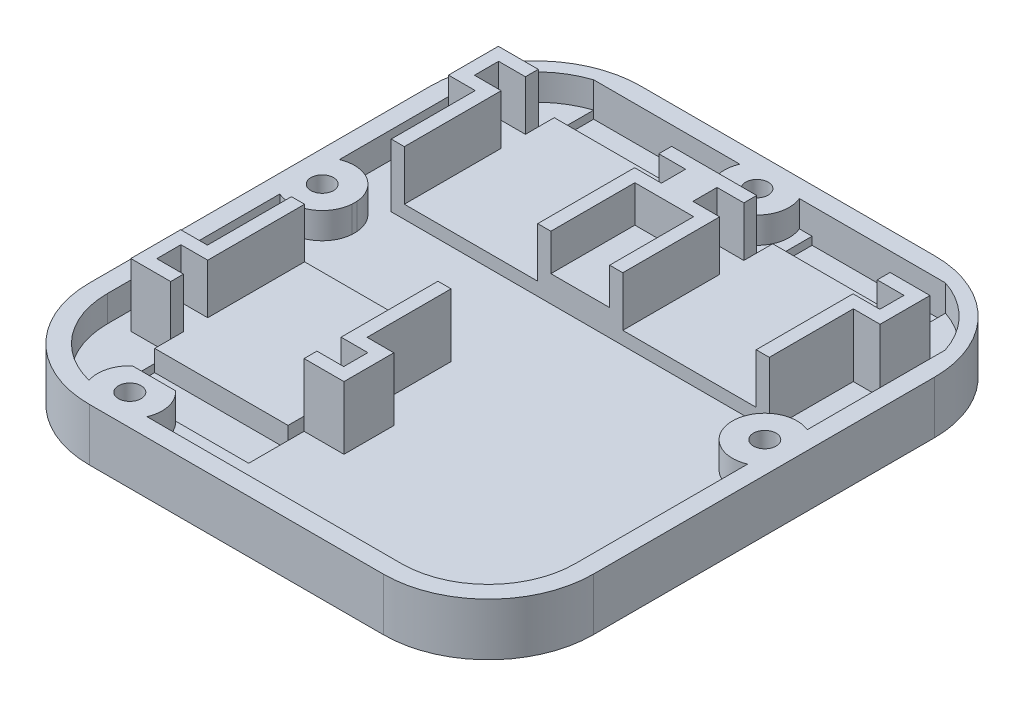
from build123d import *

# Parameters (mm, degrees)
BASE_DEPTH                                        = 10
HOLE_FOR_ACTUATOR_COVERS_DEPTH                    = 5
SIDE_CLAMPS_DEPTH                                 = 7
SKETCH14_W                                        = 25.4
SKETCH14_H                                        = 7.5
PULLEY_CLEARANCES_DEPTH                           = 6.5
CSK_FOR_8_FLAT_HEAD_SOCKET_CAP_SCREW1_D           = 4.3053
CSK_FOR_8_FLAT_HEAD_SOCKET_CAP_SCREW1_CSINK_D     = 9.1186
CSK_FOR_8_FLAT_HEAD_SOCKET_CAP_SCREW1_CSINK_ANGLE = 82
ACTUATOR_GROOVE_DEPTH                             = 2.5
MATERIAL_CUTAWAY_DEPTH                            = 5


with BuildPart() as part:
    # Sketch1 → base (new body)
    with BuildSketch(Plane(origin=(0, 0, 0), x_dir=(1, 0, 0), z_dir=(0, 1, 0))):
        with BuildLine():
            Line((-28, 52.5), (28, 52.5))
            ThreePointArc((28, 52.5), (42.142135624, 46.642135624), (48, 32.5))
            Line((48, 32.5), (48, -32.5))
            ThreePointArc((48, -32.5), (42.142135624, -46.642135624), (28, -52.5))
            Line((28, -52.5), (-28, -52.5))
            ThreePointArc((-28, -52.5), (-42.142135624, -46.642135624), (-48, -32.5))
            Line((-48, -32.5), (-48, 32.5))
            ThreePointArc((-48, 32.5), (-42.142135624, 46.642135624), (-28, 52.5))
        make_face()
    extrude(amount=BASE_DEPTH)

    # Sketch10 → hole for actuator covers (cut)
    with BuildSketch(Plane(origin=(0, 10, 0), x_dir=(1, 0, 0), z_dir=(0, 1, 0))):
        Polygon((-5.6, 5.5), (-5.6, 13), (-8.6, 13), (-33, 13), (-36, 13), (-36, 5.5), align=None)
        Polygon((33, 13), (36, 13), (36, 5.5), (5.6, 5.5), (5.6, 13), (8.6, 13), align=None)
        Polygon((-5.6, -6), (-8.6, -6), (-33, -6), (-36, -6), (-36, 1.5), (-5.6, 1.5), align=None)
    extrude(amount=-HOLE_FOR_ACTUATOR_COVERS_DEPTH, mode=Mode.SUBTRACT)

    # Sketch13 → side clamps (add)
    with BuildSketch(Plane(origin=(0, 10, 0), x_dir=(1, 0, 0), z_dir=(0, 1, 0))):
        Polygon((-8.1, -24.45), (-3, -24.45), (-3, -29.05), (-8.1, -29.05), (-8.1, -31.5), (-0.5, -31.5), (-0.5, -22), (-5.6, -22), (-5.6, -6), (-8.1, -6), align=None)
        Polygon((-41.1, 29), (-41.1, 38.5), (-33.5, 38.5), (-33.5, 36.05), (-38.6, 36.05), (-38.6, 31.45), (-33.5, 31.45), (-33.5, 13), (-36, 13), (-36, 29), align=None)
        Polygon((-8.1, 13), (-8.1, 31.45), (-3, 31.45), (-3, 36.05), (-8.1, 36.05), (-8.1, 38.5), (8.1, 38.5), (8.1, 36.05), (3, 36.05), (3, 31.45), (8.1, 31.45), (8.1, 13), (5.6, 13), (5.6, 29), (-5.6, 29), (-5.6, 13), align=None)
        Polygon((33.5, 13), (33.5, 31.45), (38.6, 31.45), (38.6, 36.05), (33.5, 36.05), (33.5, 38.5), (41.1, 38.5), (41.1, 29), (36, 29), (36, 13), align=None)
        Polygon((-38.6, -24.45), (-38.6, -29.05), (-33.5, -29.05), (-33.5, -31.5), (-41.1, -31.5), (-41.1, -22), (-36, -22), (-36, -6), (-33.5, -6), (-33.5, -24.45), align=None)
    extrude(amount=SIDE_CLAMPS_DEPTH)

    # Sketch14 → pulley clearances (cut)
    with BuildSketch(Plane(origin=(0, 10, 0), x_dir=(1, 0, 0), z_dir=(0, 1, 0))):
        with Locations((-20.8, -38.3)):
            Rectangle(SKETCH14_W, SKETCH14_H)
        with Locations((-20.8, 45.3)):
            Rectangle(SKETCH14_W, SKETCH14_H)
        with Locations((20.8, 45.3)):
            Rectangle(SKETCH14_W, SKETCH14_H)
    extrude(amount=-PULLEY_CLEARANCES_DEPTH, mode=Mode.SUBTRACT)

    # CSK for #8 Flat Head Socket Cap Screw1 (through all)
    with Locations(Plane(origin=(0, 0, 0), x_dir=(-1, 0, 0), z_dir=(0, -1, 0))):
        with Locations((26.142135624, -46.642135624), (42.142135624, 6), (0, 46.642135624), (-42.142135624, 6)):
            CounterSinkHole(CSK_FOR_8_FLAT_HEAD_SOCKET_CAP_SCREW1_D / 2, CSK_FOR_8_FLAT_HEAD_SOCKET_CAP_SCREW1_CSINK_D / 2, counter_sink_angle=CSK_FOR_8_FLAT_HEAD_SOCKET_CAP_SCREW1_CSINK_ANGLE)

    # Sketch18 → actuator groove (cut)
    with BuildSketch(Plane(origin=(0, 10, 0), x_dir=(1, 0, 0), z_dir=(0, 1, 0))):
        Polygon((-33.5, 31.45), (-33.5, 13), (-8.1, 13), (-8.1, 31.45), (-3, 31.45), (-3, 36.05), (-8.1, 36.05), (-8.1, 41.55), (-33.5, 41.55), (-33.5, 36.05), (-38.6, 36.05), (-38.6, 31.45), align=None)
        Polygon((38.6, 31.45), (38.6, 36.05), (33.5, 36.05), (33.5, 41.55), (8.1, 41.55), (8.1, 36.05), (3, 36.05), (3, 31.45), (8.1, 31.45), (8.1, 13), (33.5, 13), (33.5, 31.45), align=None)
        Polygon((-33.5, -6), (-33.5, -24.45), (-38.6, -24.45), (-38.6, -29.05), (-33.5, -29.05), (-33.5, -34.55), (-8.1, -34.55), (-8.1, -29.05), (-3, -29.05), (-3, -24.45), (-8.1, -24.45), (-8.1, -6), align=None)
    extrude(amount=-ACTUATOR_GROOVE_DEPTH, mode=Mode.SUBTRACT)

    # Sketch20 → material cutaway (cut)
    with BuildSketch(Plane(origin=(0, 10, 0), x_dir=(1, 0, 0), z_dir=(0, 1, 0))):
        with BuildLine():
            Line((-36, -6), (-5.6, -6))
            Line((-5.6, -6), (-5.6, -22))
            Line((-5.6, -22), (-0.5, -22))
            Line((-0.5, -22), (-0.5, -31.5))
            Line((-0.5, -31.5), (-8.1, -31.5))
            Line((-8.1, -31.5), (-8.1, -42.05))
            Line((-8.1, -42.05), (-22.032619784, -42.05))
            ThreePointArc((-22.032619784, -42.05), (-20.127795479, -45.29917522), (-20.469568377, -49.05))
            Line((-20.469568377, -49.05), (28, -49.05))
            ThreePointArc((28, -49.05), (39.702617229, -44.202617229), (44.55, -32.5))
            Line((44.55, -32.5), (44.55, 0.327432754))
            ThreePointArc((44.55, 0.327432754), (38.952298885, 0.727356298), (36, 5.5))
            ThreePointArc((36, 5.5), (38.535011833, 10.996447536), (44.55, 11.672567246))
            Line((44.55, 11.672567246), (44.55, 37.948525732))
            ThreePointArc((44.55, 37.948525732), (40.344819956, 44.812963205), (33.5, 49.05))
            Line((33.5, 49.05), (8.1, 49.05))
            Line((8.1, 49.05), (5.672567246, 49.05))
            ThreePointArc((5.672567246, 49.05), (0, 40.479682377), (-5.672567246, 49.05))
            Line((-5.672567246, 49.05), (-8.1, 49.05))
            Line((-8.1, 49.05), (-33.5, 49.05))
            ThreePointArc((-33.5, 49.05), (-40.344819956, 44.812963205), (-44.55, 37.948525732))
            Line((-44.55, 37.948525732), (-44.55, 11.672567246))
            ThreePointArc((-44.55, 11.672567246), (-35.979682377, 6), (-44.55, 0.327432754))
            Line((-44.55, 0.327432754), (-44.55, -32.5))
            ThreePointArc((-44.55, -32.5), (-41.039944494, -42.691287828), (-31.998658901, -48.559677051))
            ThreePointArc((-31.998658901, -48.559677051), (-32.093980526, -45.044834063), (-30.251651463, -42.05))
            Line((-30.251651463, -42.05), (-33.5, -42.05))
            Line((-33.5, -42.05), (-33.5, -31.5))
            Line((-33.5, -31.5), (-41.1, -31.5))
            Line((-41.1, -31.5), (-41.1, -22))
            Line((-41.1, -22), (-36, -22))
            Line((-36, -22), (-36, -6))
        make_face()
        Polygon((-8.1, 38.5), (-8.1, 41.55), (-33.5, 41.55), (-33.5, 38.5), (-41.1, 38.5), (-41.1, 29), (-36, 29), (-36, 13), (36, 13), (36, 29), (41.1, 29), (41.1, 38.5), (33.5, 38.5), (33.5, 41.55), (8.1, 41.55), (8.1, 38.5), align=None, mode=Mode.SUBTRACT)
    extrude(amount=-MATERIAL_CUTAWAY_DEPTH, mode=Mode.SUBTRACT)


solid = part.part
